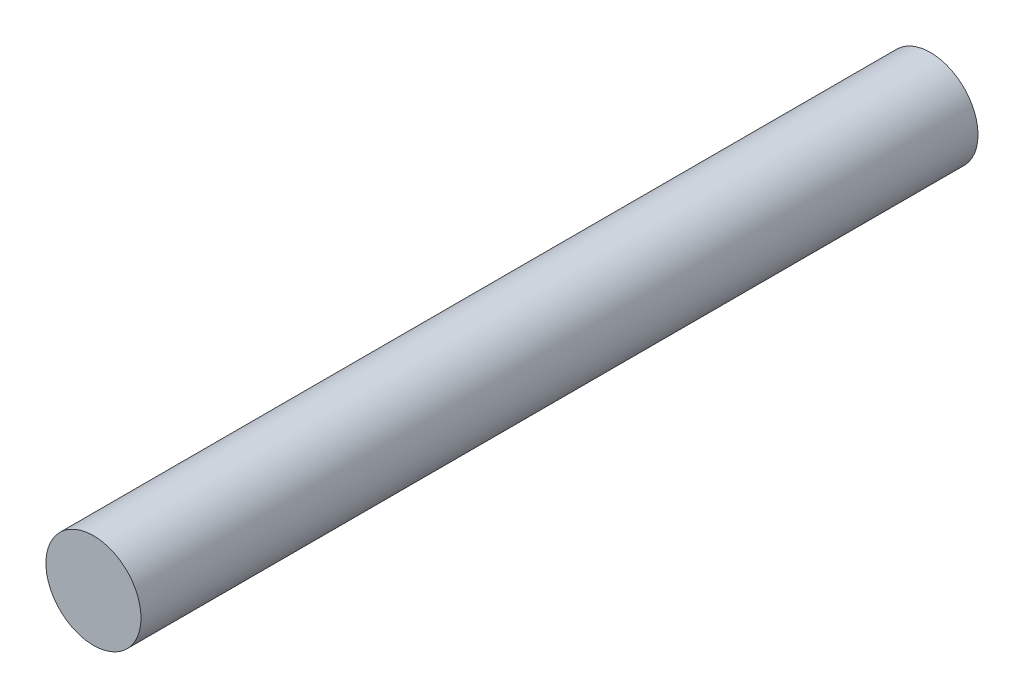
from build123d import *

# Parameters (mm, degrees)
SKETCH1_R           = 1.5875
BOSS_EXTRUDE1_DEPTH = 27.94


with BuildPart() as part:
    # Sketch1 → Boss-Extrude1 (new body)
    with BuildSketch(Plane.XY):
        Circle(SKETCH1_R)
    extrude(amount=BOSS_EXTRUDE1_DEPTH)


solid = part.part
